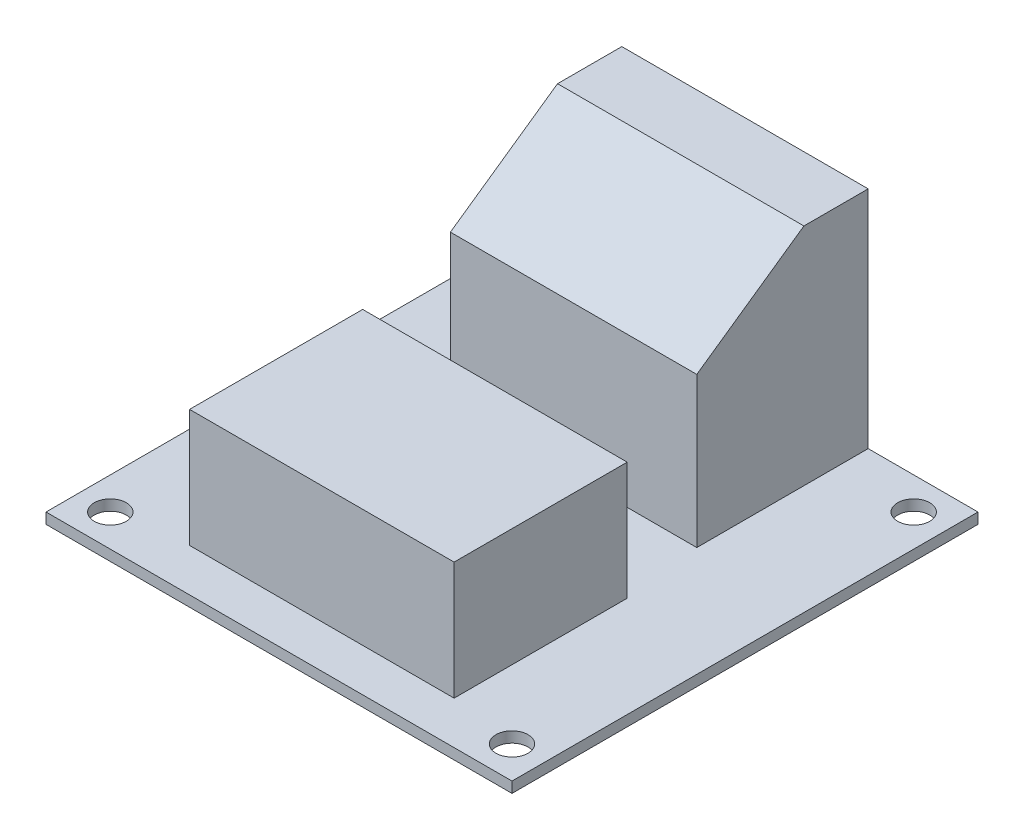
from build123d import *

# Parameters (mm, degrees)
CROQUIS1_W              = 43.5
CROQUIS1_H              = 43.5
CROQUIS1_R              = 1.5
SALIENTE_EXTRUIR1_DEPTH = 1
CROQUIS2_W              = 23
CROQUIS2_H              = 16
SALIENTE_EXTRUIR2_DEPTH = 21
CROQUIS3_W              = 24.693378616
CROQUIS3_H              = 16.159035638
SALIENTE_EXTRUIR3_DEPTH = 11
CHAFL_N1_SIZE           = 7
CHAFL_N1_SIZE2          = 10


with BuildPart() as part:
    # Croquis1 → Saliente-Extruir1 (new body)
    with BuildSketch(Plane(origin=(0, 0, 0), x_dir=(1, 0, 0), z_dir=(0, 1, 0))):
        Rectangle(CROQUIS1_W, CROQUIS1_H)
        with Locations((-18.75, 18.75)):
            Circle(CROQUIS1_R, mode=Mode.SUBTRACT)
        with Locations((18.75, 18.75)):
            Circle(CROQUIS1_R, mode=Mode.SUBTRACT)
        with Locations((18.75, -18.75)):
            Circle(CROQUIS1_R, mode=Mode.SUBTRACT)
        with Locations((-18.75, -18.75)):
            Circle(CROQUIS1_R, mode=Mode.SUBTRACT)
    extrude(amount=SALIENTE_EXTRUIR1_DEPTH)

    # Croquis2 → Saliente-Extruir2 (add)
    with BuildSketch(Plane(origin=(0, 1, 0), x_dir=(1, 0, 0), z_dir=(0, 1, 0))):
        with Locations((0, 13.75)):
            Rectangle(CROQUIS2_W, CROQUIS2_H)
    extrude(amount=SALIENTE_EXTRUIR2_DEPTH)

    # Croquis3 → Saliente-Extruir3 (add)
    with BuildSketch(Plane(origin=(0, 1, 0), x_dir=(1, 0, 0), z_dir=(0, 1, 0))):
        with Locations((0, -9.671859961)):
            Rectangle(CROQUIS3_W, CROQUIS3_H)
    extrude(amount=SALIENTE_EXTRUIR3_DEPTH)

    # Chaflán1
    chafl_n1_edges = [part.edges().sort_by_distance(p)[0] for p in [
        (0, 22, -5.75),
    ]]
    chafl_n1_side = [part.faces().sort_by_distance(p)[0] for p in [
        (0, 11.5, -5.75),
    ]]
    chamfer(chafl_n1_edges, length=CHAFL_N1_SIZE, length2=CHAFL_N1_SIZE2, reference=chafl_n1_side[0])


solid = part.part
